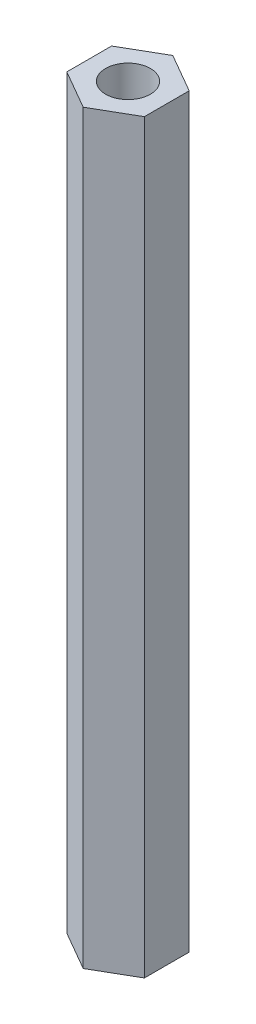
from build123d import *

# Parameters (mm, degrees)
SKETCH1_R           = 1.5
BOSS_EXTRUDE2_DEPTH = 50


with BuildPart() as part:
    # Sketch1 → Boss-Extrude2 (new body)
    with BuildSketch(Plane(origin=(0, 0, 0), x_dir=(1, 0, 0), z_dir=(0, 1, 0))):
        Polygon((0, 3.0022214), (-2.6, 1.5011107), (-2.6, -1.5011107), (0, -3.0022214), (2.6, -1.5011107), (2.6, 1.5011107), align=None)
        Circle(SKETCH1_R, mode=Mode.SUBTRACT)
    extrude(amount=BOSS_EXTRUDE2_DEPTH)


solid = part.part
